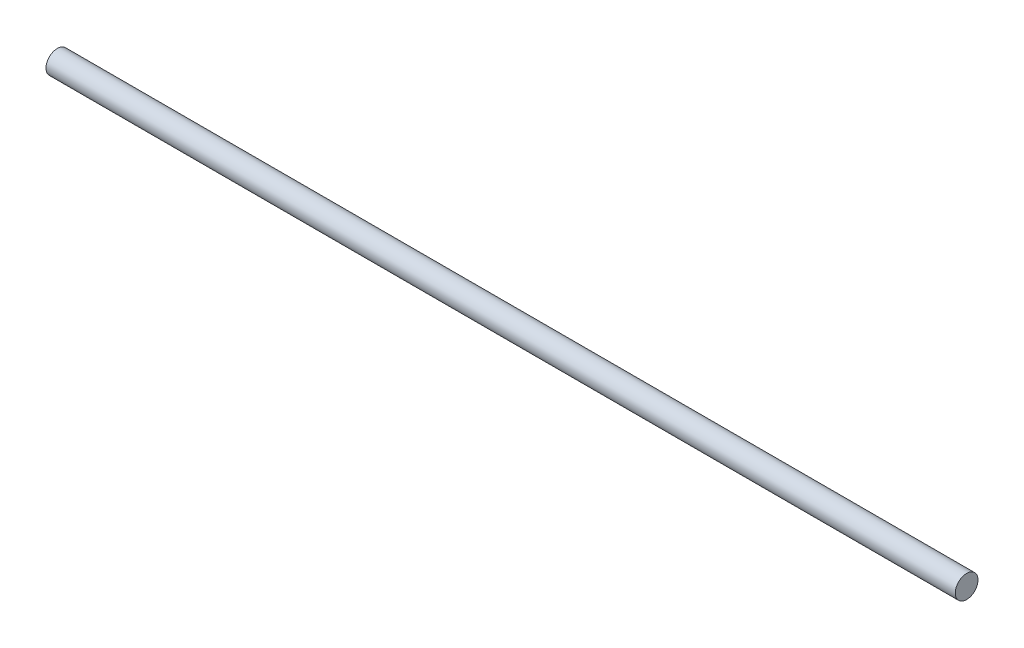
from build123d import *

# Parameters (mm, degrees)
SKETCH1_W = 120
SKETCH1_H = 1.5


with BuildPart() as part:
    # Sketch1 → Revolve1 (revolve)
    with BuildSketch(Plane.XY):
        with Locations((14.020291014, 4.729059394)):
            Rectangle(SKETCH1_W, SKETCH1_H)
    revolve(axis=Axis((74.020291014, 3.979059394, 0), (-1, 0, 0)))


solid = part.part
